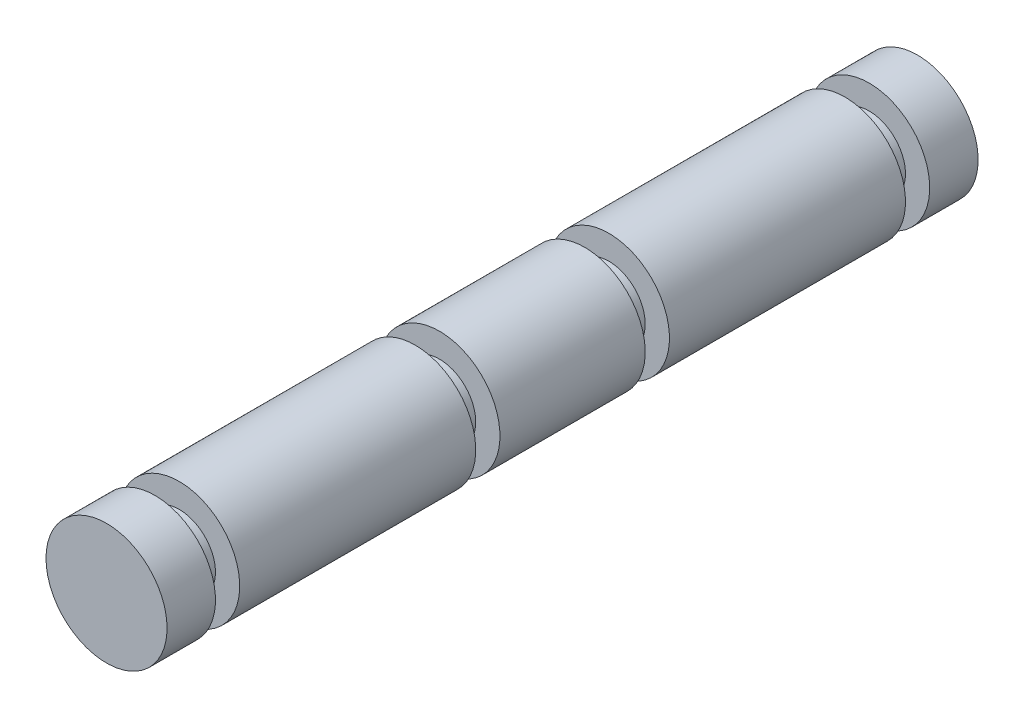
from build123d import *


with BuildPart() as part:
    # Sketch2 → Revolve1 (revolve)
    with BuildSketch(Plane(origin=(0, 0, 0), x_dir=(1, 0, 0), z_dir=(0, 1, 0))):
        Polygon((0, 0), (0, 67), (-5, 67), (-5, 63), (-3, 63), (-3, 61), (-5, 61), (-5, 41.5), (-3, 41.5), (-3, 39.5), (-5, 39.5), (-5, 27.5), (-3, 27.5), (-3, 25.5), (-5, 25.5), (-5, 6), (-3, 6), (-3, 4), (-5, 4), (-5, 0), align=None)
    revolve(axis=Axis((0, 0, -67), (0, 0, 1)))


solid = part.part
